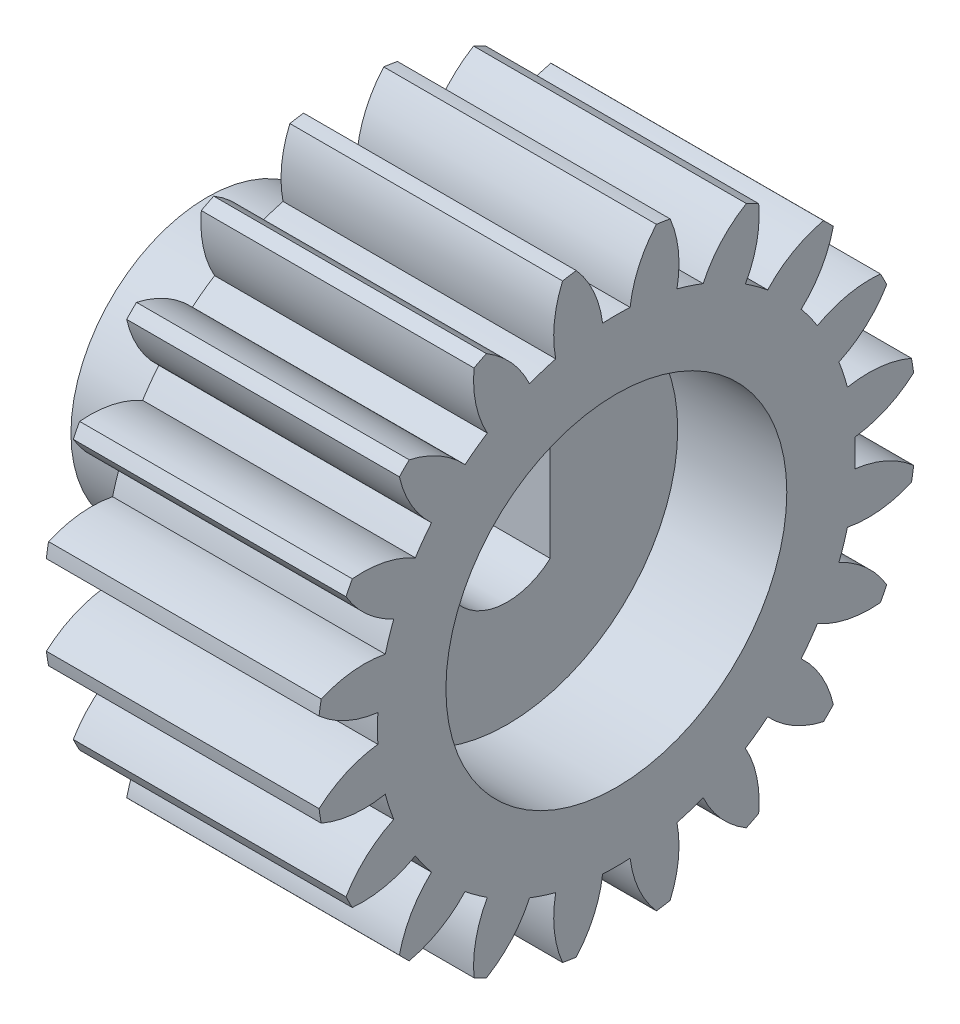
from build123d import *

# Parameters (mm, degrees)
BASPROSKE_W         = 12.7
BASPROSKE_H         = 13.97
TOOTHCUT_DEPTH      = 24.486417351
TEETHCUTS_COUNT     = 20
HUBNEAONESKE_R      = 6.35
HUBNEARONE_DEPTH    = 6.3502032
BORSKE_R            = 3.175
BORE_DEPTH          = 19.0502032
SKETCH1_R           = 3.175
BOSS_EXTRUDE1_DEPTH = 19.0502032
SKETCH2_R           = 7.9375
CUT_EXTRUDE1_DEPTH  = 5.08


with BuildPart() as part:
    # BasProSke → Base-Revolve (revolve)
    with BuildSketch(Plane(origin=(0, 0, 0), x_dir=(1, 0, 0), z_dir=(0, 1, 0)), mode=Mode.PRIVATE) as base_revolve_sk:
        with Locations((6.35, 6.985)):
            Rectangle(BASPROSKE_W, BASPROSKE_H)
    revolve(base_revolve_sk.sketch.rotate(Axis((-10, 0, 0), (1, 0, 0)), 180), axis=Axis((-10, 0, 0), (1, 0, 0)))

    # TooCutSke → ToothCut (cut, through all)
    with BuildSketch(Plane(origin=(0, 0, 0), x_dir=(0, 0, -1), z_dir=(1, 0, 0))):
        with BuildLine():
            ThreePointArc((0.64046545, 11.106749257), (0, 11.1252), (-0.64046545, 11.106749257))
            ThreePointArc((-0.64046545, 11.106749257), (-1.052455812, 12.582227662), (-1.8855699, 13.867798935))
            ThreePointArc((-1.8855699, 13.867798935), (0, 13.9954), (1.8855699, 13.867798935))
            ThreePointArc((1.8855699, 13.867798935), (1.052455812, 12.582227662), (0.64046545, 11.106749257))
        make_face()
    toothcut = extrude(amount=TOOTHCUT_DEPTH, mode=Mode.SUBTRACT)

    # TeethCuts: ToothCut ×20 about axis
    teethcuts_axis = Axis((-10, 0, 0), (1, 0, 0))
    for i in range(1, TEETHCUTS_COUNT):
        add(toothcut.rotate(teethcuts_axis, i * 360 / TEETHCUTS_COUNT), mode=Mode.SUBTRACT)

    # HubNeaOneSke → HubNearOne (add)
    with BuildSketch(Plane.ZY):
        with Locations(Location((0, 0, 0), (0, 0, 180))):
            Circle(HUBNEAONESKE_R)
    extrude(amount=HUBNEARONE_DEPTH)

    # BorSke → Bore (cut, symmetric)
    with BuildSketch(Plane(origin=(0, 0, 0), x_dir=(0, 0, -1), z_dir=(1, 0, 0))):
        with Locations(Location((0, 0, 0), (0, 0, 180))):
            Circle(BORSKE_R)
    extrude(amount=BORE_DEPTH, both=True, mode=Mode.SUBTRACT)

    # Sketch1 → Boss-Extrude1 (add)
    with BuildSketch(Plane.ZY.offset(6.3502032)):
        Circle(SKETCH1_R)
        with BuildLine():
            Line((-2, 2.236067977), (-2, -2.236067977))
            ThreePointArc((-2, -2.236067977), (3, 0), (-2, 2.236067977))
        make_face(mode=Mode.SUBTRACT)
    extrude(amount=-BOSS_EXTRUDE1_DEPTH)

    # Sketch2 → Cut-Extrude1 (cut)
    with BuildSketch(Plane(origin=(12.7, 0, 0), x_dir=(0, 0, -1), z_dir=(1, 0, 0))):
        Circle(SKETCH2_R)
    extrude(amount=-CUT_EXTRUDE1_DEPTH, mode=Mode.SUBTRACT)


solid = part.part
